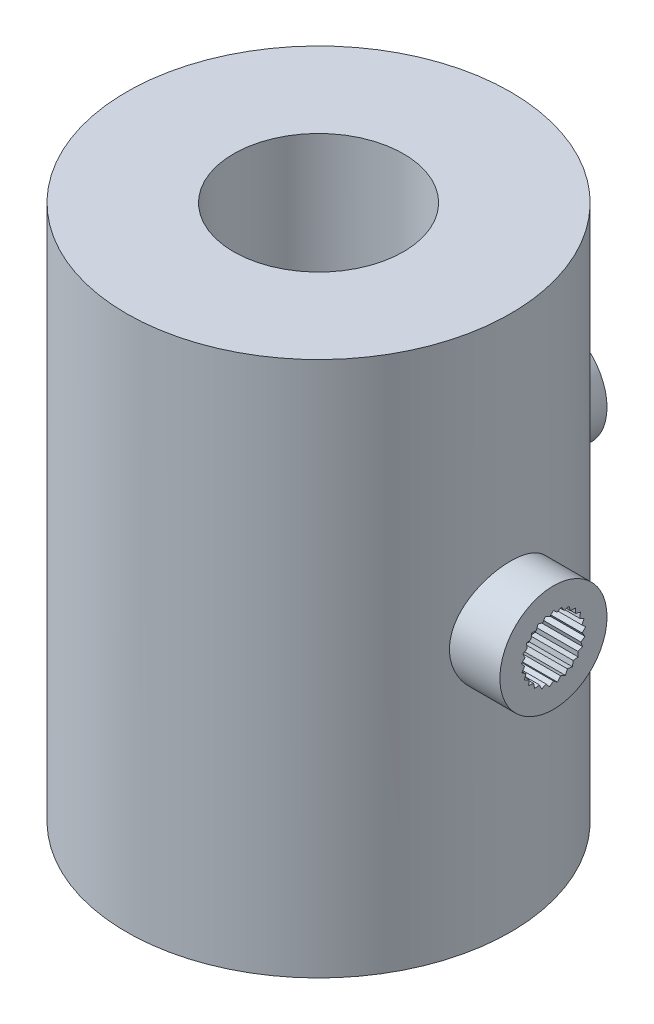
from build123d import *
from build123d.topology import SkipClean

# Parameters (mm, degrees)
SKETCH1_R                = 17.928932
BOSS_EXTRUDE1_DEPTH      = 10
SKETCH2_R                = 7.928932
CUT_EXTRUDE1_DEPTH       = 28.256068
BOSS_EXTRUDE2_REACH      = 46.834
BOSS_EXTRUDE2_END_RADIUS = 17.928932
SKETCH4_R                = 5
BOSS_EXTRUDE5_REACH      = 48.578
BOSS_EXTRUDE5_END_RADIUS = 17.928932
SKETCH11_R               = 5
CUT_EXTRUDE5_DEPTH       = 4
CIRPATTERN1_COUNT        = 2
CIRPATTERN1_ANGLE        = 270
SKETCH21_R               = 7.928932
BOSS_EXTRUDE6_DEPTH      = 20
SKETCH22_R               = 7.928932
BOSS_EXTRUDE7_DEPTH      = 20


with BuildPart() as part:
    # Sketch1 → Boss-Extrude1 (new body)
    with BuildSketch(Plane(origin=(0, 0, 0), x_dir=(1, 0, 0), z_dir=(0, 1, 0))):
        with Locations(Location((0, 0, 0), (0, 0, 270))):
            Circle(SKETCH1_R)
    extrude(amount=BOSS_EXTRUDE1_DEPTH)

    # Sketch2 → Cut-Extrude1 (cut, through all)
    with BuildSketch(Plane(origin=(0, 10, 0), x_dir=(1, 0, 0), z_dir=(0, 1, 0))):
        with Locations(Location((0, 0, 0), (0, 0, 270))):
            Circle(SKETCH2_R)
    extrude(amount=-CUT_EXTRUDE1_DEPTH, mode=Mode.SUBTRACT)

    # Boss-Extrude2: up to this cylinder (the profile starts outside it)
    with SkipClean():  # the faces are left unmerged after this step: merging them gives an invalid solid
        boss_extrude2_end = Plane(origin=(0, 5, 0), z_dir=(0, -1, 0)) * Cylinder(BOSS_EXTRUDE2_END_RADIUS, 130.525864, mode=Mode.PRIVATE)
        # Sketch4 → Boss-Extrude2 (add, up to the surface)
        with BuildSketch(Plane(origin=(21.928932, 0, 0), x_dir=(0, 0, -1), z_dir=(1, 0, 0)), mode=Mode.PRIVATE) as boss_extrude2_sk1:
            with Locations((0, 5)):
                Circle(SKETCH4_R)
        boss_extrude2_tool1 = extrude(boss_extrude2_sk1.sketch, amount=-BOSS_EXTRUDE2_REACH, mode=Mode.PRIVATE) - boss_extrude2_end
        add(boss_extrude2_tool1.solids().sort_by_distance((21.928932, 5, 0))[0])

    # Boss-Extrude5: up to this cylinder (the profile starts outside it)
    boss_extrude5_end = Plane(origin=(0, 5, 0), z_dir=(0, -1, 0)) * Cylinder(BOSS_EXTRUDE5_END_RADIUS, 134.013864, mode=Mode.PRIVATE)
    # Sketch11 → Boss-Extrude5 (add, up to the surface)
    with BuildSketch(Plane.XY.offset(-21.928932), mode=Mode.PRIVATE) as boss_extrude5_sk1:
        with Locations(Location((0, 5, 0), (0, 0, 270))):
            Circle(SKETCH11_R)
    boss_extrude5_tool1 = extrude(boss_extrude5_sk1.sketch, amount=BOSS_EXTRUDE5_REACH, mode=Mode.PRIVATE) - boss_extrude5_end
    add(boss_extrude5_tool1.solids().sort_by_distance((0, 5, -21.928932))[0])

    # Sketch14 → Cut-Extrude5 (cut)
    with BuildSketch(Plane(origin=(0, 0, -21.928932), x_dir=(-1, 0, 0), z_dir=(0, 0, -1))):
        Polygon((0, 8), (-0.33838, 7.678553), (-0.74607, 7.905749), (-0.993878, 7.510249), (-1.445261, 7.62892), (-1.586927, 7.184218), (-2.053641, 7.186906), (-2.080264, 6.720944), (-2.532984, 6.60748), (-2.44289, 6.149537), (-2.85317, 5.927051), (-2.65202, 5.5059), (-2.99408, 5.188372), (-2.694514, 4.830476), (-2.946862, 4.437856), (-2.567702, 4.165703), (-2.714481, 3.722662), (-2.279552, 3.553353), (-2.31154, 3.087728), (-1.848169, 3.0319), (-1.763356, 2.572949), (-1.300659, 2.634111), (-1.104374, 2.210671), (-0.671423, 2.384979), (-0.376, 2.023656), (0, 2.300158), (0.376, 2.023656), (0.671423, 2.384979), (1.104374, 2.210671), (1.300659, 2.634111), (1.763356, 2.572949), (1.848169, 3.0319), (2.31154, 3.087728), (2.279552, 3.553353), (2.714481, 3.722662), (2.567702, 4.165703), (2.946862, 4.437856), (2.694514, 4.830476), (2.99408, 5.188372), (2.65202, 5.5059), (2.85317, 5.927051), (2.44289, 6.149537), (2.532984, 6.60748), (2.080264, 6.720944), (2.053641, 7.186906), (1.586927, 7.184218), (1.445261, 7.62892), (0.993878, 7.510249), (0.74607, 7.905749), (0.33838, 7.678553), align=None)
    cut_extrude5 = extrude(amount=-CUT_EXTRUDE5_DEPTH, mode=Mode.SUBTRACT)

    # CirPattern1: Cut-Extrude5 ×2 about axis
    cirpattern1_axis = Axis((0, 0, 0), (0, 1, 0))
    for i in range(1, CIRPATTERN1_COUNT):
        add(cut_extrude5.rotate(cirpattern1_axis, i * CIRPATTERN1_ANGLE / (CIRPATTERN1_COUNT - 1)), mode=Mode.SUBTRACT)

    # Sketch21 → Boss-Extrude6 (add)
    with BuildSketch(Plane(origin=(0, 10, 0), x_dir=(1, 0, 0), z_dir=(0, 1, 0))):
        with BuildLine():
            ThreePointArc((17.928932, 0), (12.67767, 12.67767), (0, 17.928932))
            ThreePointArc((0, 17.928932), (-12.67767, -12.67767), (17.928932, 0))
        make_face()
        with Locations(Location((0, 0, 0), (0, 0, 270))):
            Circle(SKETCH21_R, mode=Mode.SUBTRACT)
    extrude(amount=BOSS_EXTRUDE6_DEPTH)

    # Sketch22 → Boss-Extrude7 (add)
    with BuildSketch(Plane.XZ):
        with BuildLine():
            ThreePointArc((0, -17.928932), (12.67767, -12.67767), (17.928932, 0))
            ThreePointArc((17.928932, 0), (-12.67767, 12.67767), (0, -17.928932))
        make_face()
        with Locations(Location((0, 0, 0), (0, 0, 90))):
            Circle(SKETCH22_R, mode=Mode.SUBTRACT)
    extrude(amount=BOSS_EXTRUDE7_DEPTH)


solid = part.part
